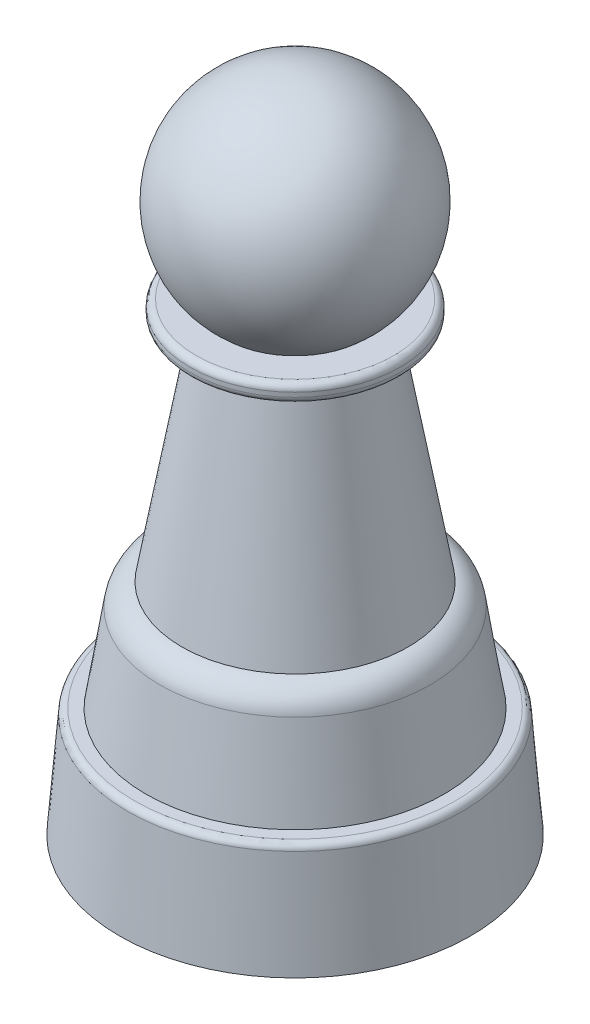
from build123d import *


with BuildPart() as part:
    # Sketch3 → Revolve3 (revolve)
    with BuildSketch(Plane(origin=(0, 0, 0), x_dir=(0, 0, -1), z_dir=(1, 0, 0))):
        with BuildLine():
            ThreePointArc((7.976750754, 22.176677088), (11.759040062, 36.040371448), (0, 44.300680797))
            Line((0, 44.300680797), (0, 22.176677088))
            Line((0, 22.176677088), (0, 20.176677088))
            Line((0, 20.176677088), (0, 19.300680797))
            Line((0, 19.300680797), (0, -18.199319203))
            Line((0, -18.199319203), (0, -30.699319203))
            Line((0, -30.699319203), (17.300215532, -30.699319203))
            Line((17.300215532, -30.699319203), (20, -30.699319203))
            Line((20, -30.699319203), (19.055215287, -18.889510286))
            ThreePointArc((19.055215287, -18.889510286), (18.816349006, -18.398249022), (18.307603828, -18.199319203))
            Line((18.307603828, -18.199319203), (17, -18.199319203))
            Line((17, -18.199319203), (15.404164559, -8.225347699))
            ThreePointArc((15.404164559, -8.225347699), (14.556848822, -6.571703413), (12.898197127, -5.734232256))
            Line((12.898197127, -5.734232256), (8.329404716, 20.176677088))
            Line((8.329404716, 20.176677088), (11.25, 20.176677088))
            ThreePointArc((11.25, 20.176677088), (11.780330086, 20.396347002), (12, 20.926677088))
            Line((12, 20.926677088), (12, 21.426677088))
            ThreePointArc((12, 21.426677088), (11.780330086, 21.957007173), (11.25, 22.176677088))
            Line((11.25, 22.176677088), (7.976750754, 22.176677088))
        make_face()
    revolve(axis=Axis((0, 63.905153842, 0), (0, -1, 0)))


solid = part.part
